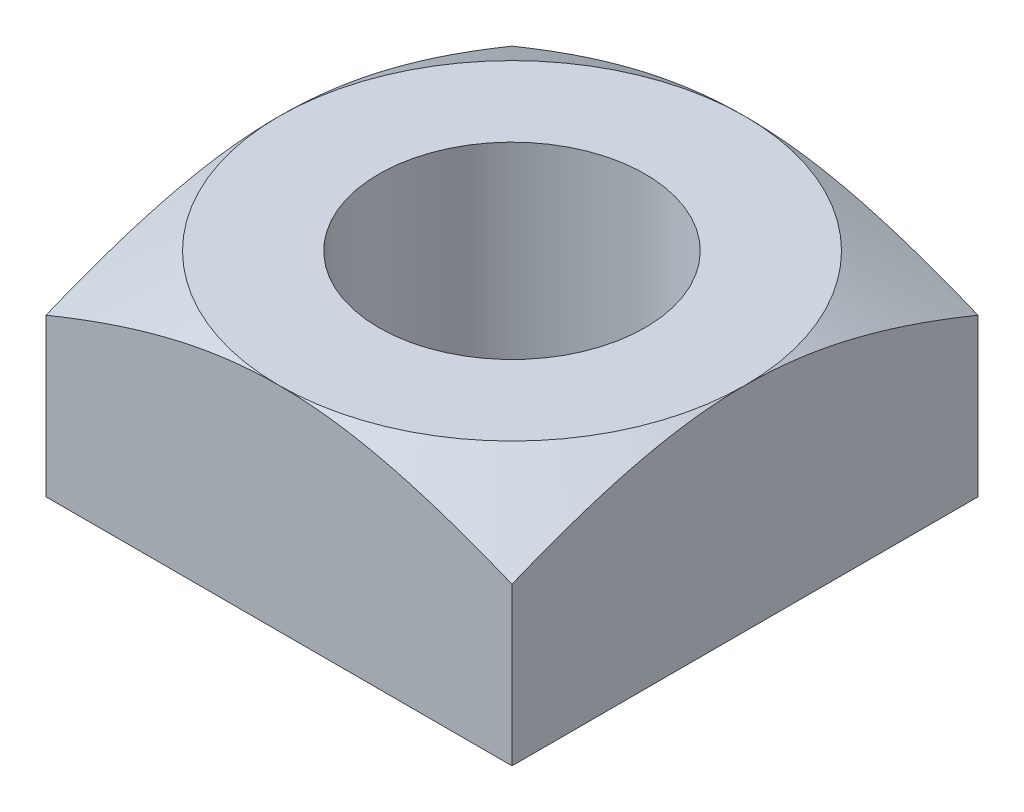
from build123d import *

# Parameters (mm, degrees)
SKETCH1_W           = 7
SKETCH1_H           = 7
SKETCH1_R           = 2
BOSS_EXTRUDE1_DEPTH = 1.6
SKETCH5_OUTSIDE_W   = 34.962
SKETCH5_OUTSIDE_H   = 34.962
SKETCH5_OUTSIDE_R   = 3.5
CUT_EXTRUDE2_DEPTH  = 6.894064811
CUT_EXTRUDE2_DRAFT  = -60


with BuildPart() as part:
    # Sketch1 → Boss-Extrude1 (new, symmetric)
    with BuildSketch(Plane(origin=(0, 0, 0), x_dir=(1, 0, 0), z_dir=(0, 1, 0))):
        Rectangle(SKETCH1_W, SKETCH1_H)
        Circle(SKETCH1_R, mode=Mode.SUBTRACT)
    extrude(amount=BOSS_EXTRUDE1_DEPTH, both=True)


with BuildPart() as cut_extrude2_tool:
    # Sketch5 outside → Cut-Extrude2 (with draft: the straight prism first)
    with BuildSketch(Plane(origin=(0, 1.6, 0), x_dir=(1, 0, 0), z_dir=(0, 1, 0))):
        Rectangle(SKETCH5_OUTSIDE_W, SKETCH5_OUTSIDE_H)
        Circle(SKETCH5_OUTSIDE_R, mode=Mode.SUBTRACT)
    extrude(amount=-CUT_EXTRUDE2_DEPTH)
    # Cut-Extrude2: the draft: its side faces are tilted about the plane it starts from
    cut_extrude2_sides = [cut_extrude2_tool.faces().sort_by_distance(p)[0] for p in [
        (0, -1.847032406, 17.481),
        (17.481, -1.847032406, 0),
        (0, -1.847032406, -17.481),
        (-17.481, -1.847032406, 0),
        (-3.5, -1.847032406, 0),
    ]]
    draft(cut_extrude2_sides, Plane(origin=(0, 1.6, 0), x_dir=(1, 0, 0), z_dir=(0, 1, 0)), CUT_EXTRUDE2_DRAFT)


with BuildPart() as part_1:
    add(part.part)

    # Cut-Extrude2: cut by cut_extrude2_tool
    add(cut_extrude2_tool.part, mode=Mode.SUBTRACT)


solid = part_1.part
